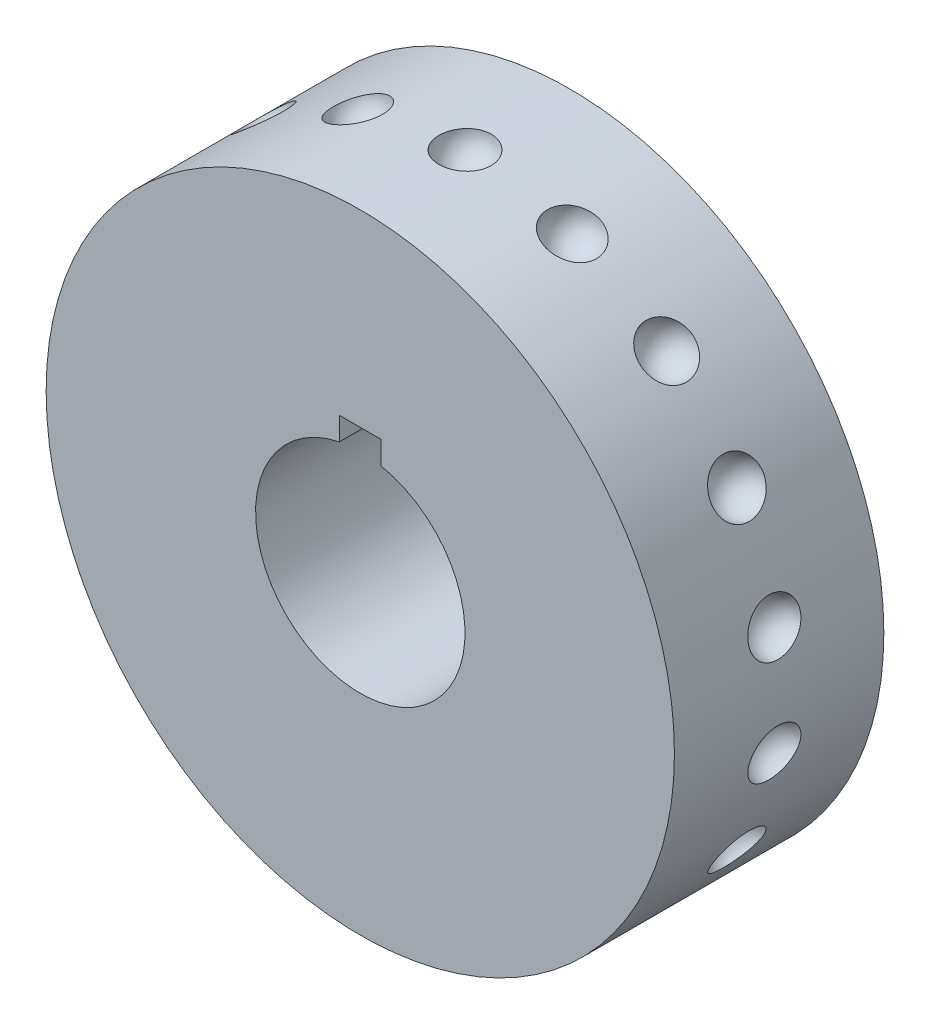
from build123d import *
from build123d.topology import SkipClean

# Parameters (mm, degrees)
ESQUISSE1_R                  = 30
BOSS_EXTRU_1_DEPTH           = 20
ESQUISSE2_R                  = 25
ESQUISSE2_R_2                = 17
ENL_V_MAT_EXTRU_1_DEPTH      = 15
ESQUISSE3_R                  = 10
ENL_V_MAT_EXTRU_2_DEPTH      = 21
ESQUISSE4_W                  = 4
ESQUISSE4_H                  = 12
ENL_V_MAT_EXTRU_3_DEPTH      = 21
R_P_TITION_CIRCULAIRE1_COUNT = 18


with BuildPart() as part:
    # Esquisse1 → Boss.-Extru.1 (new body)
    with BuildSketch(Plane.XY):
        Circle(ESQUISSE1_R)
    extrude(amount=BOSS_EXTRU_1_DEPTH)

    # Esquisse2 → Enl_v. mat.-Extru.1 (cut)
    with BuildSketch(Plane.XY):
        Circle(ESQUISSE2_R)
        Circle(ESQUISSE2_R_2, mode=Mode.SUBTRACT)
    extrude(amount=ENL_V_MAT_EXTRU_1_DEPTH, mode=Mode.SUBTRACT)

    # Esquisse3 → Enl_v. mat.-Extru.2 (cut, through all)
    with BuildSketch(Plane.XY):
        Circle(ESQUISSE3_R)
    extrude(amount=ENL_V_MAT_EXTRU_2_DEPTH, mode=Mode.SUBTRACT)

    # Esquisse4 → Enl_v. mat.-Extru.3 (cut, through all)
    with BuildSketch(Plane.XY):
        with Locations((0, 6)):
            Rectangle(ESQUISSE4_W, ESQUISSE4_H)
    extrude(amount=ENL_V_MAT_EXTRU_3_DEPTH, mode=Mode.SUBTRACT)

    # Esquisse7 → Enl_vement de mati_re-R_volution6 (revolve, cut)
    with SkipClean():  # keep this step's faces unmerged: merging them makes the solid invalid here
        with BuildSketch(Plane(origin=(0, 0, 0), x_dir=(0, 0, -1), z_dir=(1, 0, 0))):
            with BuildLine():
                Line((-12.5, 30), (-7.5, 30))
                ThreePointArc((-7.5, 30), (-10, 27.5), (-12.5, 30))
            make_face()
        enl_vement_de_mati_re_r_volution6 = revolve(axis=Axis((0, 30, -1), (0, 0, 1)), mode=Mode.SUBTRACT)

    # R_p_tition circulaire1: Enl_vement de mati_re-R_volution6 ×18 about axis
    with SkipClean():  # keep this step's faces unmerged: merging them makes the solid invalid here
        r_p_tition_circulaire1_axis = Axis((0, 0, 0), (0, 0, 1))
        for i in range(1, R_P_TITION_CIRCULAIRE1_COUNT):
            add(enl_vement_de_mati_re_r_volution6.rotate(r_p_tition_circulaire1_axis, i * 360 / R_P_TITION_CIRCULAIRE1_COUNT), mode=Mode.SUBTRACT)


solid = part.part
